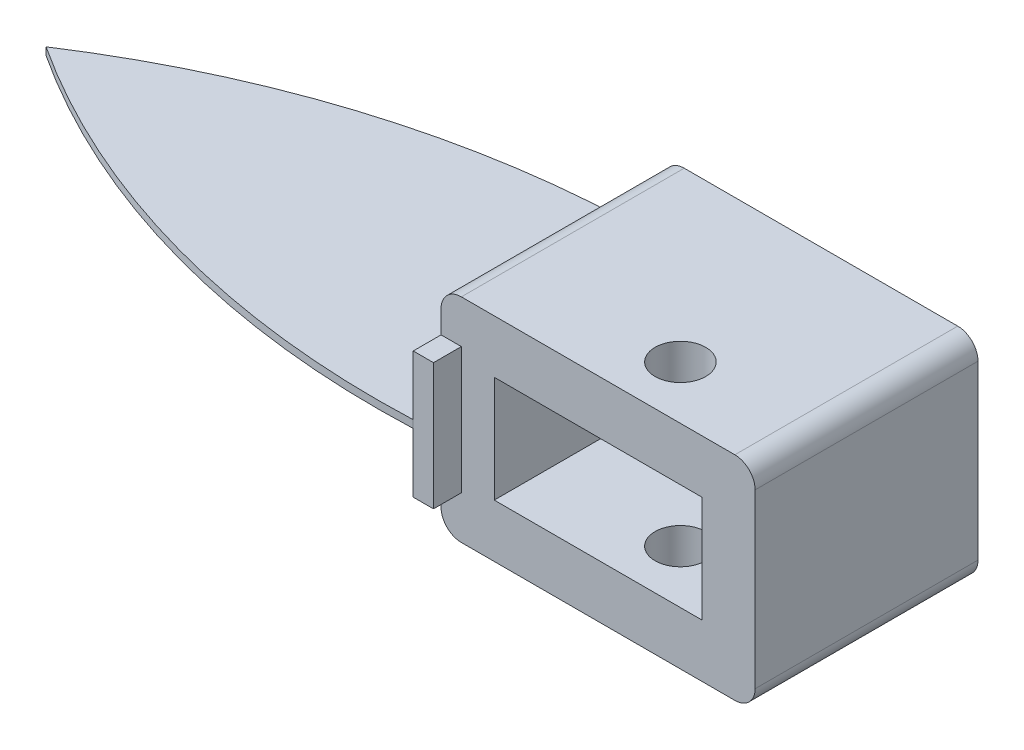
from build123d import *

# Parameters (mm, degrees)
SKETCH1_W           = 62
SKETCH1_H           = 42
SKETCH1_W_2         = 41
SKETCH1_H_2         = 21
BOSS_EXTRUDE1_DEPTH = 43
SKETCH2_W           = 4
SKETCH2_H           = 25
BOSS_EXTRUDE2_DEPTH = 5.5
SKETCH_1_R          = 5
CUT_EXTRUDE_1_DEPTH = 42
SKETCH_2_W          = 41
SKETCH_2_H          = 21
SKETCH_2_R          = 7
EXTRUDE_1_DEPTH     = 1
SKETCH_2_3_W        = 62
SKETCH_2_3_H        = 42
SKETCH_2_3_R        = 7
EXTRUDE_2_DEPTH     = 1
FILLET_1_R          = 4
FILLET_2_R          = 4
FILLET_3_R          = 4
FILLET_4_R          = 4
SKETCH2_3_W         = 4
SKETCH2_3_H         = 25
EXTRUDE_3_DEPTH     = 49.5
EXTRUDE_4_DEPTH     = 0.75
EXTRUDE_5_DEPTH     = 0.75


with BuildPart() as part:
    # Sketch1 → Boss-Extrude1 (new body)
    with BuildSketch(Plane.XY):
        with Locations((1.904162196, -4.136072895)):
            Rectangle(SKETCH1_W, SKETCH1_H)
        with Locations((1.904162196, -4.136072895)):
            Rectangle(SKETCH1_W_2, SKETCH1_H_2, mode=Mode.SUBTRACT)
    extrude(amount=BOSS_EXTRUDE1_DEPTH)

    # Sketch2 → Boss-Extrude2 (add)
    with BuildSketch(Plane.XY.offset(43)):
        with Locations((-27.095837804, -4.136072895)):
            Rectangle(SKETCH2_W, SKETCH2_H)
    extrude(amount=BOSS_EXTRUDE2_DEPTH)

    # Sketch 1 → Cut-Extrude 1 (cut)
    with BuildSketch(Plane(origin=(0, 16.863927105, 0), x_dir=(1, 0, 0), z_dir=(0, 1, 0))):
        with Locations((7.653776732, -32.500385465)):
            Circle(SKETCH_1_R)
    extrude(amount=-CUT_EXTRUDE_1_DEPTH, mode=Mode.SUBTRACT)

    # Sketch 2 → Extrude 1 (add)
    with BuildSketch(Plane(origin=(0, 0, 0), x_dir=(-1, 0, 0), z_dir=(0, 0, -1))):
        with Locations((-1.904162196, -4.136072895)):
            Rectangle(SKETCH_2_W, SKETCH_2_H)
        with Locations((-12.404162196, -4.136072895)):
            Circle(SKETCH_2_R, mode=Mode.SUBTRACT)
    extrude(amount=-EXTRUDE_1_DEPTH)

    # Sketch 2_3 → Extrude 2 (add)
    with BuildSketch(Plane(origin=(0, 0, 0), x_dir=(-1, 0, 0), z_dir=(0, 0, -1))):
        with Locations((-1.904162196, -4.136072895)):
            Rectangle(SKETCH_2_3_W, SKETCH_2_3_H)
        with Locations((-12.404162196, -4.136072895)):
            Circle(SKETCH_2_3_R, mode=Mode.SUBTRACT)
    extrude(amount=EXTRUDE_2_DEPTH)

    # Fillet 1
    fillet_1_edges = [part.edges().sort_by_distance(p)[0] for p in [
        (32.904162196, -25.136072895, 21),
    ]]
    fillet(fillet_1_edges, radius=FILLET_1_R)

    # Fillet 2
    fillet_2_edges = [part.edges().sort_by_distance(p)[0] for p in [
        (-29.095837804, -25.136072895, 21),
    ]]
    fillet(fillet_2_edges, radius=FILLET_2_R)

    # Fillet 3
    fillet_3_edges = [part.edges().sort_by_distance(p)[0] for p in [
        (32.904162196, 16.863927105, 21),
    ]]
    fillet(fillet_3_edges, radius=FILLET_3_R)

    # Fillet 4
    fillet_4_edges = [part.edges().sort_by_distance(p)[0] for p in [
        (-29.095837804, 16.863927105, 21),
    ]]
    fillet(fillet_4_edges, radius=FILLET_4_R)

    # Sketch2_3 → Extrude 3 (add)
    with BuildSketch(Plane.XY.offset(43)):
        with Locations((-27.095837804, -4.136072895)):
            Rectangle(SKETCH2_3_W, SKETCH2_3_H)
    extrude(amount=-EXTRUDE_3_DEPTH)

    # Sketch 5 → Extrude 4 (add)
    with BuildSketch(Plane(origin=(0, -4.136072895, 0), x_dir=(1, 0, 0), z_dir=(0, 1, 0))):
        with BuildLine():
            Line((-29.095837804, -21), (-29.095837804, 6.5))
            ThreePointArc((-29.095837804, 6.5), (-81.244156023, 0.562066252), (-129.095837804, -21))
            Line((-129.095837804, -21), (-29.095837804, -21))
        make_face()
        with BuildLine():
            Line((-29.095837804, -48.5), (-29.095837804, -21))
            Line((-29.095837804, -21), (-129.095837804, -21))
            ThreePointArc((-129.095837804, -21), (-81.244156023, -42.562066252), (-29.095837804, -48.5))
        make_face()
    extrude(amount=EXTRUDE_4_DEPTH)

    # Sketch 5_3 → Extrude 5 (add)
    with BuildSketch(Plane(origin=(0, -4.136072895, 0), x_dir=(1, 0, 0), z_dir=(0, 1, 0))):
        with BuildLine():
            Line((-29.095837804, -21), (-29.095837804, 6.5))
            ThreePointArc((-29.095837804, 6.5), (-81.244156023, 0.562066252), (-129.095837804, -21))
            Line((-129.095837804, -21), (-29.095837804, -21))
        make_face()
        with BuildLine():
            Line((-29.095837804, -48.5), (-29.095837804, -21))
            Line((-29.095837804, -21), (-129.095837804, -21))
            ThreePointArc((-129.095837804, -21), (-81.244156023, -42.562066252), (-29.095837804, -48.5))
        make_face()
    extrude(amount=-EXTRUDE_5_DEPTH)


solid = part.part
